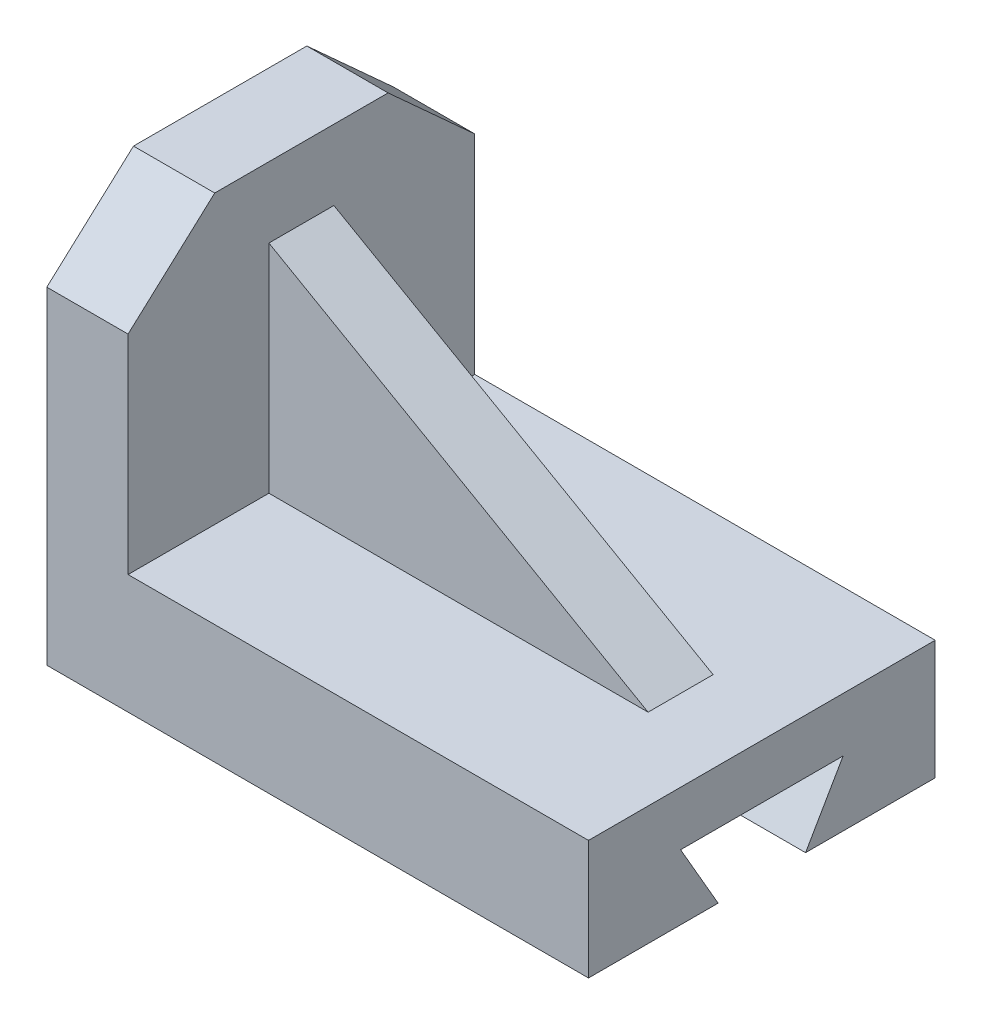
from build123d import *

# Parameters (mm, degrees)
BOSS_EXTRUDE2_DEPTH = 32
CUT_EXTRUDE2_DEPTH  = 21
CUT_EXTRUDE3_DEPTH  = 21
CUT_EXTRUDE4_DEPTH  = 5
CUT_EXTRUDE5_DEPTH  = 5
CUT_EXTRUDE6_REACH  = 17
CUT_EXTRUDE7_REACH  = 102


with BuildPart() as part:
    # Sketch1 → Boss-Extrude2 (new body, symmetric)
    with BuildSketch(Plane.XY):
        Polygon((-13.146933892, 26.49867374), (56.853066108, -13.50132626), (-13.146933892, -13.50132626), align=None)
        Polygon((-13.146933892, 26.49867374), (-13.146933892, -13.50132626), (56.853066108, -13.50132626), (71.853066108, -13.50132626), (71.853066108, -35.50132626), (-28.146933892, -35.50132626), (-28.146933892, 39.49867374), (-13.146933892, 39.49867374), align=None)
    extrude(amount=BOSS_EXTRUDE2_DEPTH, both=True)

    # Sketch3 → Cut-Extrude2 (cut)
    with BuildSketch(Plane.XY.offset(32)):
        Polygon((-13.146933892, 26.49867374), (-13.146933892, -13.50132626), (56.853066108, -13.50132626), align=None)
    extrude(amount=-CUT_EXTRUDE2_DEPTH, mode=Mode.SUBTRACT)

    # Sketch4 → Cut-Extrude3 (cut)
    with BuildSketch(Plane(origin=(0, 0, -32), x_dir=(-1, 0, 0), z_dir=(0, 0, -1))):
        Polygon((13.146933892, 26.49867374), (13.146933892, -13.50132626), (-56.853066108, -13.50132626), align=None)
    extrude(amount=-CUT_EXTRUDE3_DEPTH, mode=Mode.SUBTRACT)

    # Sketch8 → Cut-Extrude4 (cut)
    with BuildSketch(Plane.XY.offset(11)):
        Polygon((-13.146933892, 26.49867374), (56.853066108, -13.50132626), (-13.146933892, -13.50132626), align=None)
    extrude(amount=-CUT_EXTRUDE4_DEPTH, mode=Mode.SUBTRACT)

    # Sketch9 → Cut-Extrude5 (cut)
    with BuildSketch(Plane(origin=(0, 0, -11), x_dir=(-1, 0, 0), z_dir=(0, 0, -1))):
        Polygon((13.146933892, 26.49867374), (-56.853066108, -13.50132626), (13.146933892, -13.50132626), align=None)
    extrude(amount=-CUT_EXTRUDE5_DEPTH, mode=Mode.SUBTRACT)

    # Sketch10 → Cut-Extrude6 (cut, up to next)
    with BuildSketch(Plane(origin=(-13.146933892, 0, 0), x_dir=(0, 0, -1), z_dir=(1, 0, 0)), mode=Mode.PRIVATE) as cut_extrude6_sk1:
        Polygon((-16, 39.49867374), (-32, 39.49867374), (-32, 24.946500862), align=None)
    cut_extrude6_tool1 = extrude(cut_extrude6_sk1.sketch, amount=-CUT_EXTRUDE6_REACH, mode=Mode.PRIVATE) & part.part
    add(cut_extrude6_tool1.solids().sort_by_distance((-13.146934, 34.647949, 26.666667))[0], mode=Mode.SUBTRACT)
    # Sketch10 → Cut-Extrude6 (cut, up to next)
    with BuildSketch(Plane(origin=(-13.146933892, 0, 0), x_dir=(0, 0, -1), z_dir=(1, 0, 0)), mode=Mode.PRIVATE) as cut_extrude6_sk2:
        Polygon((32, 39.49867374), (16, 39.49867374), (32, 24.946500862), align=None)
    cut_extrude6_tool2 = extrude(cut_extrude6_sk2.sketch, amount=-CUT_EXTRUDE6_REACH, mode=Mode.PRIVATE) & part.part
    add(cut_extrude6_tool2.solids().sort_by_distance((-13.146934, 34.647949, -26.666667))[0], mode=Mode.SUBTRACT)

    # Sketch11 → Cut-Extrude7 (cut, up to next)
    with BuildSketch(Plane(origin=(71.853066108, 0, 0), x_dir=(0, 0, -1), z_dir=(1, 0, 0)), mode=Mode.PRIVATE) as cut_extrude7_sk1:
        Polygon((-8.07179677, -35.50132626), (8.07179677, -35.50132626), (15, -23.50132626), (-15, -23.50132626), align=None)
    cut_extrude7_tool1 = extrude(cut_extrude7_sk1.sketch, amount=-CUT_EXTRUDE7_REACH, mode=Mode.PRIVATE) & part.part
    add(cut_extrude7_tool1.solids().sort_by_distance((71.853066, -28.900749, 0))[0], mode=Mode.SUBTRACT)


solid = part.part
